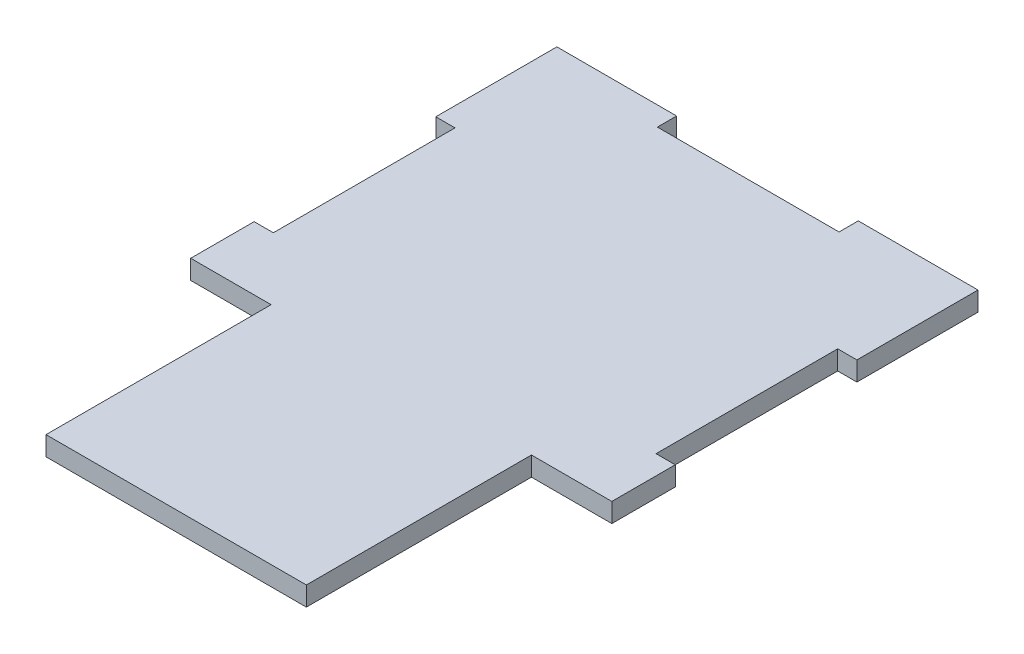
from build123d import *

# Parameters (mm, degrees)
BOSS_EXTRUDE1_DEPTH = 3.175


with BuildPart() as part:
    # Sketch1 → Boss-Extrude1 (new body)
    with BuildSketch(Plane(origin=(0, 0, 0), x_dir=(1, 0, 0), z_dir=(0, 1, 0))):
        Polygon((49.775, 91.3), (19.775, 91.3), (19.775, 94.475), (0, 94.475), (0, 74.475), (3.175, 74.475), (3.175, 44.475), (0, 44.475), (0, 34), (13.275, 34), (13.275, -3.175), (56.275, -3.175), (56.275, 34), (69.55, 34), (69.55, 44.475), (66.375, 44.475), (66.375, 74.475), (69.55, 74.475), (69.55, 94.475), (49.775, 94.475), align=None)
    extrude(amount=BOSS_EXTRUDE1_DEPTH)


solid = part.part
